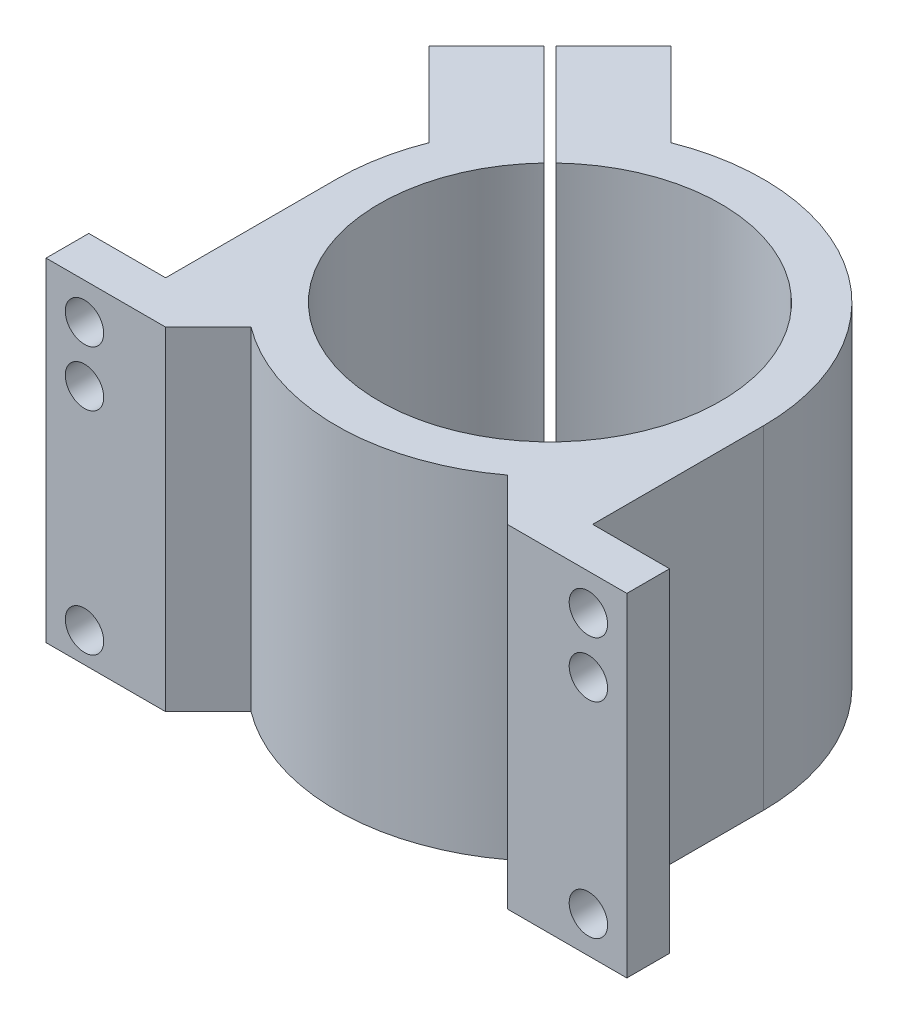
from build123d import *

# Parameters (mm, degrees)
BOSS_EXTRUDE2_DEPTH      = 78
M8_CLEARANCE_HOLE1_D     = 9
M8_CLEARANCE_HOLE1_DEPTH = 10
M8_CLEARANCE_HOLE1_TIP   = 2.703872786
M8_CLEARANCE_HOLE2_D     = 9


with BuildPart() as part:
    # Sketch1 → Boss-Extrude2 (new body)
    with BuildSketch(Plane(origin=(0, 0, 0), x_dir=(1, 0, 0), z_dir=(0, 1, 0))):
        with BuildLine():
            Line((-68, -50), (-50, -50))
            Line((-50, -50), (-40, -50))
            Line((-40, -50), (-30, -40))
            ThreePointArc((-30, -40), (0, -50), (30, -40))
            Line((30, -40), (40, -50))
            Line((40, -50), (50, -50))
            Line((50, -50), (68, -50))
            Line((68, -50), (68, -40))
            Line((68, -40), (50, -40))
            Line((50, -40), (50, 0))
            ThreePointArc((50, 0), (28.168436295, 41.310279553), (-18.261567868, 46.545839116))
            Line((-18.261567868, 46.545839116), (-37.864743155, 66.149014403))
            Line((-37.864743155, 66.149014403), (-51.299771998, 52.71398556))
            Line((-51.299771998, 52.71398556), (-27.56832425, 28.982537812))
            ThreePointArc((-27.56832425, 28.982537812), (15.76811704, 36.760936944), (40, 0))
            ThreePointArc((40, 0), (-14.84416531, -37.143650282), (-28.982537812, 27.56832425))
            Line((-28.982537812, 27.56832425), (-52.71398556, 51.299771998))
            Line((-52.71398556, 51.299771998), (-66.149014403, 37.864743155))
            Line((-66.149014403, 37.864743155), (-46.545839116, 18.261567868))
            ThreePointArc((-46.545839116, 18.261567868), (-49.128871124, 9.292686485), (-50, 0))
            Line((-50, 0), (-50, -40))
            Line((-50, -40), (-68, -40))
            Line((-68, -40), (-68, -50))
        make_face()
    extrude(amount=BOSS_EXTRUDE2_DEPTH)

    # M8 Clearance Hole1
    with Locations(Plane.XY.offset(50)):
        with Locations((-59, 69.5), (-59, 7), (-59, 56.5), (59, 56.5), (59, 8.5), (59, 69.5)):
            Hole(M8_CLEARANCE_HOLE1_D / 2, depth=M8_CLEARANCE_HOLE1_DEPTH)
            with Locations((0, 0, -(M8_CLEARANCE_HOLE1_DEPTH + M8_CLEARANCE_HOLE1_TIP / 2))):  # 118° drill point
                Cone(0, M8_CLEARANCE_HOLE1_D / 2, M8_CLEARANCE_HOLE1_TIP, mode=Mode.SUBTRACT)

    # M8 Clearance Hole2 (through all)
    with Locations(Plane(origin=(14.142135624, 0, -14.142135624), x_dir=(-0.707106781, 0, -0.707106781), z_dir=(0.707106781, 0, -0.707106781))):
        with Locations((59.687295128, 8.5), (59.687295128, 69.5)):
            Hole(M8_CLEARANCE_HOLE2_D / 2)


solid = part.part
